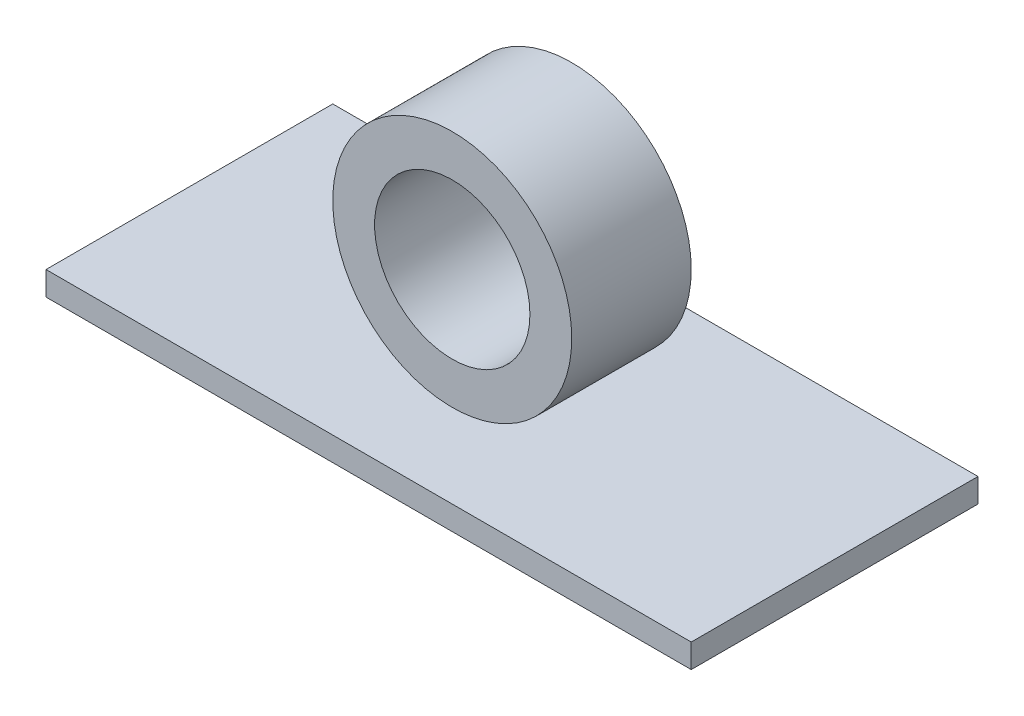
from build123d import *

# Parameters (mm, degrees)
SKETCH1_W           = 54
SKETCH1_H           = 24
BOSS_EXTRUDE1_DEPTH = 2
SKETCH2_R           = 10
SKETCH2_R_2         = 6.5
BOSS_EXTRUDE2_DEPTH = 5


with BuildPart() as part:
    # Sketch1 → Boss-Extrude1 (new body)
    with BuildSketch(Plane(origin=(0, 0, 0), x_dir=(1, 0, 0), z_dir=(0, 1, 0))):
        Rectangle(SKETCH1_W, SKETCH1_H)
    extrude(amount=BOSS_EXTRUDE1_DEPTH)


with BuildPart() as body_2:
    # Sketch2 → Boss-Extrude2 (new body, symmetric)
    with BuildSketch(Plane.XY):
        with Locations((0, 12)):
            Circle(SKETCH2_R)
        with Locations((0, 12)):
            Circle(SKETCH2_R_2, mode=Mode.SUBTRACT)
    extrude(amount=BOSS_EXTRUDE2_DEPTH, both=True)


solid = Compound([part.part, body_2.part])
